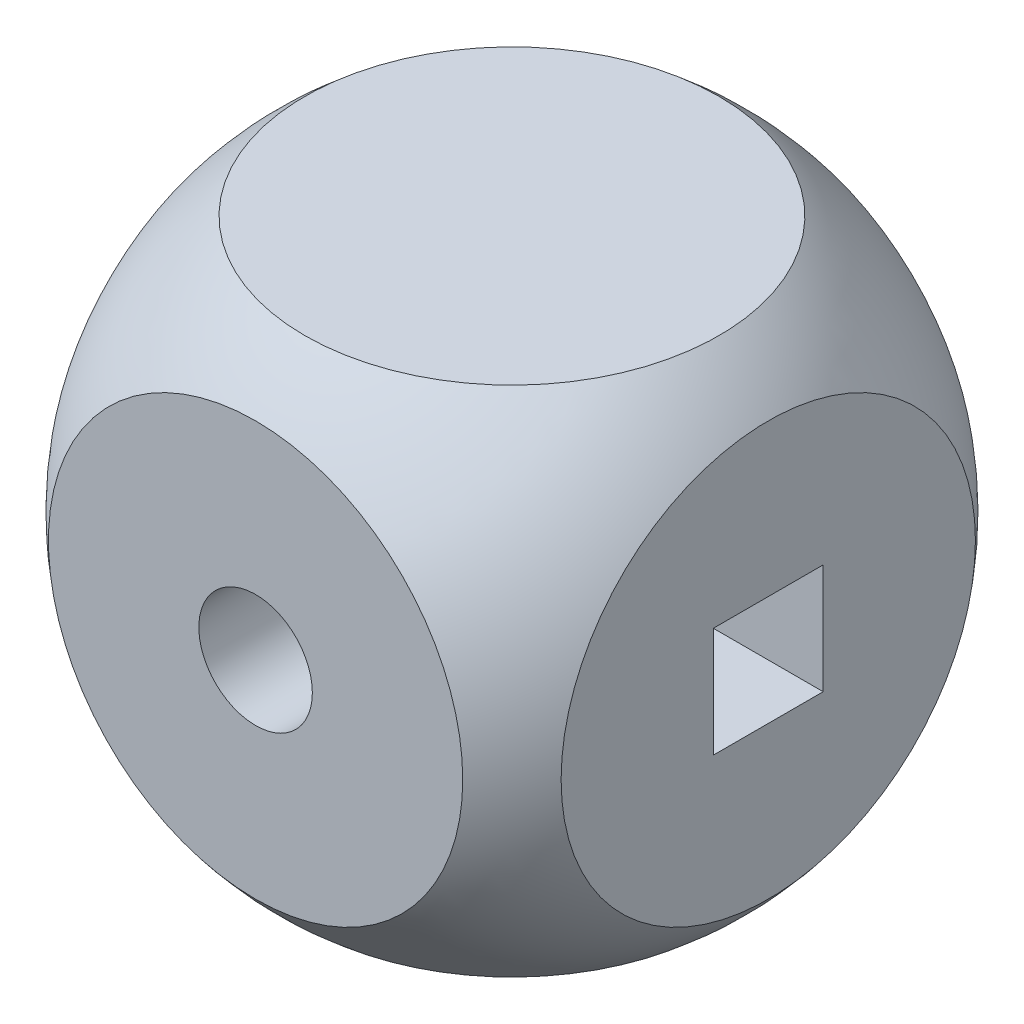
from build123d import *

# Parameters (mm, degrees)
SKETCH_6_R          = 10
CUT_EXTRUDE_4_DEPTH = 2
SKETCH_7_R          = 10
CUT_EXTRUDE_5_DEPTH = 2
SKETCH_8_R          = 10
CUT_EXTRUDE_6_DEPTH = 2
SKETCH_9_R          = 1.55
CUT_EXTRUDE_7_DEPTH = 15
SKETCH_11_W         = 3
SKETCH_11_H         = 3
CUT_EXTRUDE_9_DEPTH = 15


with BuildPart() as part:
    # 스케치1 → 회전42 (revolve)
    with BuildSketch(Plane.XY):
        with BuildLine():
            Line((0, 9), (0, -9))
            ThreePointArc((0, -9), (9, 0), (0, 9))
        make_face()
    revolve(axis=Axis((0, 9, 0), (0, -1, 0)))

    # 스케치6 → 컷-돌출4 (cut)
    with BuildSketch(Plane.XY.offset(9)):
        Circle(SKETCH_6_R)
    cut_extrude_4 = extrude(amount=-CUT_EXTRUDE_4_DEPTH, mode=Mode.SUBTRACT)

    # 대칭 복사4: 컷-돌출4 across plane
    add(cut_extrude_4.mirror(Plane.XY), mode=Mode.SUBTRACT)

    # 스케치7 → 컷-돌출5 (cut)
    with BuildSketch(Plane(origin=(0, 9, 0), x_dir=(1, 0, 0), z_dir=(0, 1, 0))):
        Circle(SKETCH_7_R)
    cut_extrude_5 = extrude(amount=-CUT_EXTRUDE_5_DEPTH, mode=Mode.SUBTRACT)

    # 대칭 복사5: 컷-돌출5 across plane
    add(cut_extrude_5.mirror(Plane.ZX), mode=Mode.SUBTRACT)

    # 스케치8 → 컷-돌출6 (cut)
    with BuildSketch(Plane(origin=(9, 0, 0), x_dir=(0, 0, -1), z_dir=(1, 0, 0))):
        Circle(SKETCH_8_R)
    cut_extrude_6 = extrude(amount=-CUT_EXTRUDE_6_DEPTH, mode=Mode.SUBTRACT)

    # 대칭 복사6: 컷-돌출6 across plane
    add(cut_extrude_6.mirror(Plane(origin=(0, 0, 0), x_dir=(0, 0, 1), z_dir=(1, 0, 0))), mode=Mode.SUBTRACT)

    # 스케치9 → 컷-돌출7 (cut, through all)
    with BuildSketch(Plane.XY.offset(7)):
        Circle(SKETCH_9_R)
    extrude(amount=-CUT_EXTRUDE_7_DEPTH, mode=Mode.SUBTRACT)

    # 스케치11 → 컷-돌출9 (cut, through all)
    with BuildSketch(Plane(origin=(7, 0, 0), x_dir=(0, 0, -1), z_dir=(1, 0, 0))):
        Rectangle(SKETCH_11_W, SKETCH_11_H)
    extrude(amount=-CUT_EXTRUDE_9_DEPTH, mode=Mode.SUBTRACT)


solid = part.part
